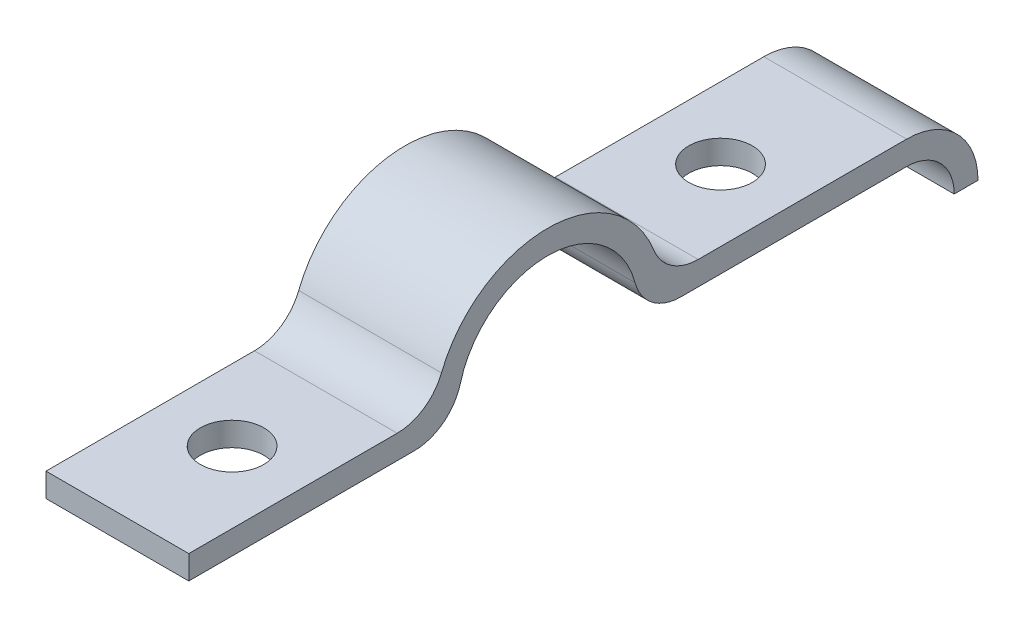
from build123d import *

# Parameters (mm, degrees)
BOSS_EXTRUDE1_DEPTH = 3.81
CUT_EXTRUDE1_REACH  = 5.81
SKETCH3_R           = 1.694754892


with BuildPart() as part:
    # Sketch2 → Boss-Extrude1 (new body, symmetric)
    with BuildSketch(Plane(origin=(0, 0, 0), x_dir=(0, 0, -1), z_dir=(1, 0, 0))):
        with BuildLine():
            Line((21.69668, -3.175), (22.96668, -3.175))
            ThreePointArc((22.96668, -3.175), (21.850756836, -0.480923164), (19.15668, 0.635))
            Line((19.15668, 0.635), (8.031181171, 0.635))
            ThreePointArc((8.031181171, 0.635), (6.602950056, 1.074581974), (5.669069062, 2.241176471))
            ThreePointArc((5.669069062, 2.241176471), (0, 6.096), (-5.669069062, 2.241176471))
            ThreePointArc((-5.669069062, 2.241176471), (-6.602950056, 1.074581974), (-8.031181171, 0.635))
            Line((-8.031181171, 0.635), (-19.15668, 0.635))
            Line((-19.15668, 0.635), (-19.15668, -0.635))
            Line((-19.15668, -0.635), (-7.115400973, -0.635))
            ThreePointArc((-7.115400973, -0.635), (-5.568940052, -0.109958714), (-4.66181443, 1.248103448))
            ThreePointArc((-4.66181443, 1.248103448), (0, 4.826), (4.66181443, 1.248103448))
            ThreePointArc((4.66181443, 1.248103448), (5.568940052, -0.109958714), (7.115400973, -0.635))
            Line((7.115400973, -0.635), (19.15668, -0.635))
            ThreePointArc((19.15668, -0.635), (20.952731224, -1.378948776), (21.69668, -3.175))
        make_face()
    extrude(amount=BOSS_EXTRUDE1_DEPTH, both=True)

    # Sketch3 → Cut-Extrude1 (cut, up to next)
    with BuildSketch(Plane(origin=(0, 0.635, 0), x_dir=(1, 0, 0), z_dir=(0, 1, 0)), mode=Mode.PRIVATE) as cut_extrude1_sk1:
        with Locations((0, 13.03528)):
            Circle(SKETCH3_R)
    cut_extrude1_tool1 = extrude(cut_extrude1_sk1.sketch, amount=-CUT_EXTRUDE1_REACH, mode=Mode.PRIVATE) & part.part
    add(cut_extrude1_tool1.solids().sort_by_distance((0, 0.635, -13.03528))[0], mode=Mode.SUBTRACT)
    # Sketch3 → Cut-Extrude1 (cut, up to next)
    with BuildSketch(Plane(origin=(0, 0.635, 0), x_dir=(1, 0, 0), z_dir=(0, 1, 0)), mode=Mode.PRIVATE) as cut_extrude1_sk2:
        with Locations((0, -13.03528)):
            Circle(SKETCH3_R)
    cut_extrude1_tool2 = extrude(cut_extrude1_sk2.sketch, amount=-CUT_EXTRUDE1_REACH, mode=Mode.PRIVATE) & part.part
    add(cut_extrude1_tool2.solids().sort_by_distance((0, 0.635, 13.03528))[0], mode=Mode.SUBTRACT)


solid = part.part
